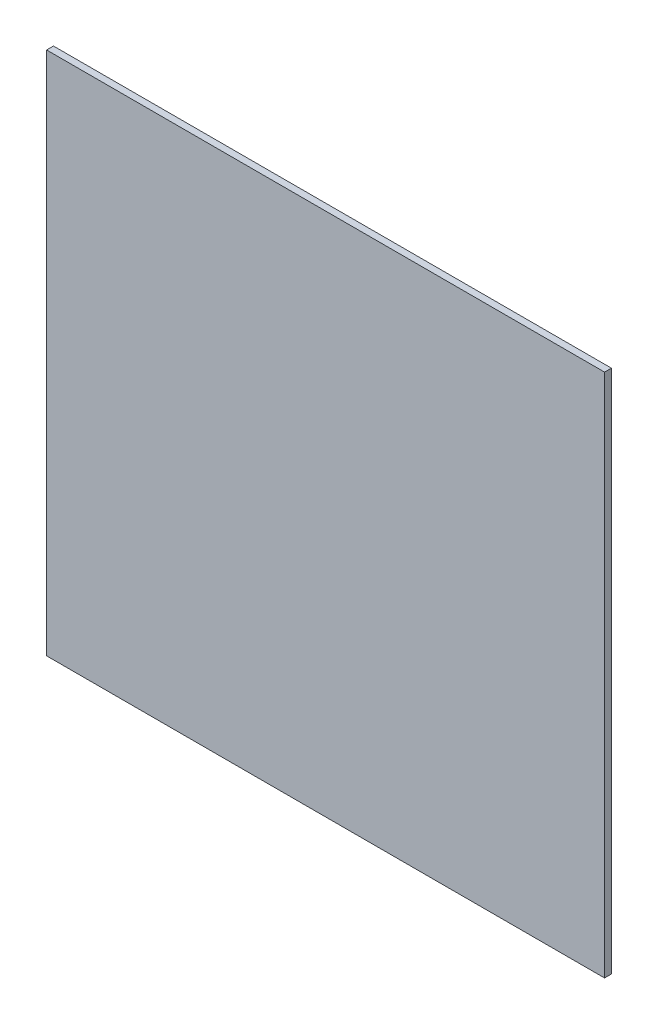
from build123d import *

# Parameters (mm, degrees)
SKETCH1_W           = 972.312
SKETCH1_H           = 914.4
BOSS_EXTRUDE1_DEPTH = 11.938


with BuildPart() as part:
    # Sketch1 → Boss-Extrude1 (new body)
    with BuildSketch(Plane.XY):
        with Locations((486.156, 457.2)):
            Rectangle(SKETCH1_W, SKETCH1_H)
    extrude(amount=BOSS_EXTRUDE1_DEPTH)


solid = part.part
